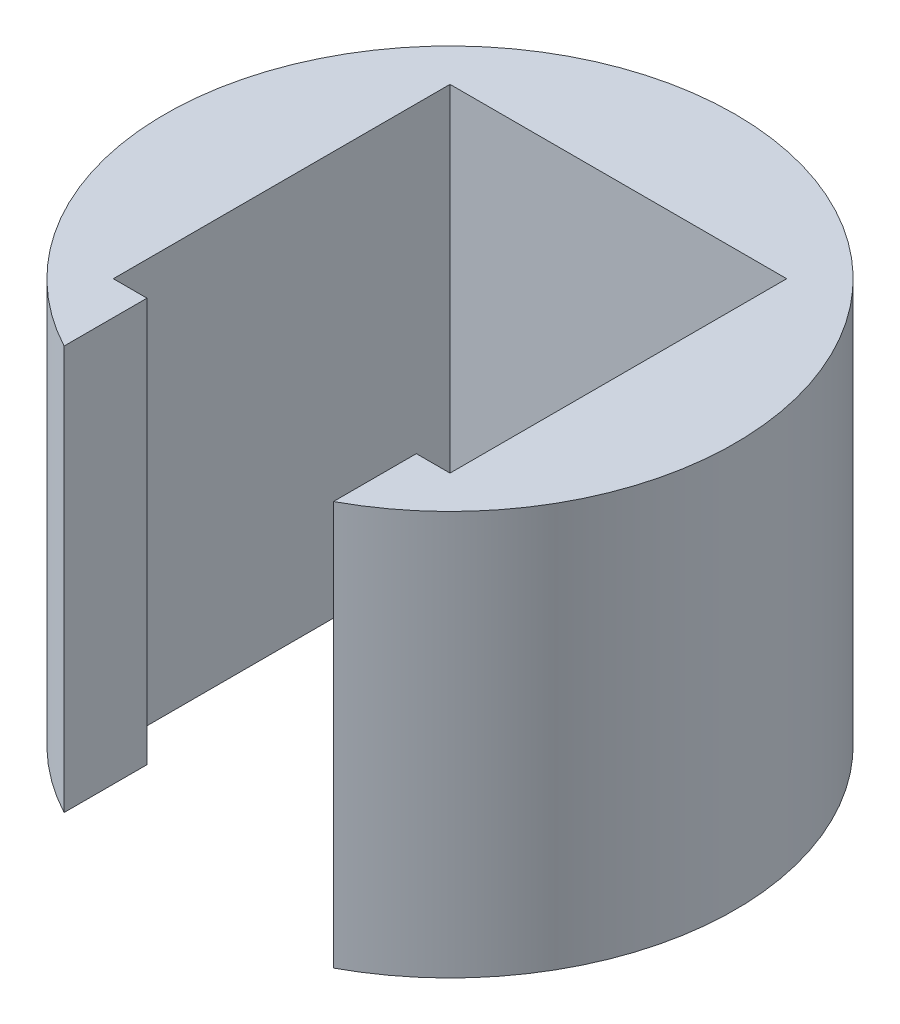
from build123d import *

# Parameters (mm, degrees)
BOSS_EXTRUDE2_DEPTH = 18


with BuildPart() as part:
    # Sketch1 → Boss-Extrude2 (new body)
    with BuildSketch(Plane(origin=(0, 0, 0), x_dir=(1, 0, 0), z_dir=(0, 1, 0))):
        with BuildLine():
            Line((5.999643171, -7.5), (7.5, -7.5))
            Line((7.5, -7.5), (7.5, 7.5))
            Line((7.5, 7.5), (-7.5, 7.5))
            Line((-7.5, 7.5), (-7.5, -7.5))
            Line((-7.5, -7.5), (-5.999643171, -7.5))
            Line((-5.999643171, -7.5), (-5.999643171, -11.193492834))
            ThreePointArc((-5.999643171, -11.193492834), (0, 12.7), (5.999643171, -11.193492834))
            Line((5.999643171, -11.193492834), (5.999643171, -7.5))
        make_face()
    extrude(amount=BOSS_EXTRUDE2_DEPTH)


solid = part.part
